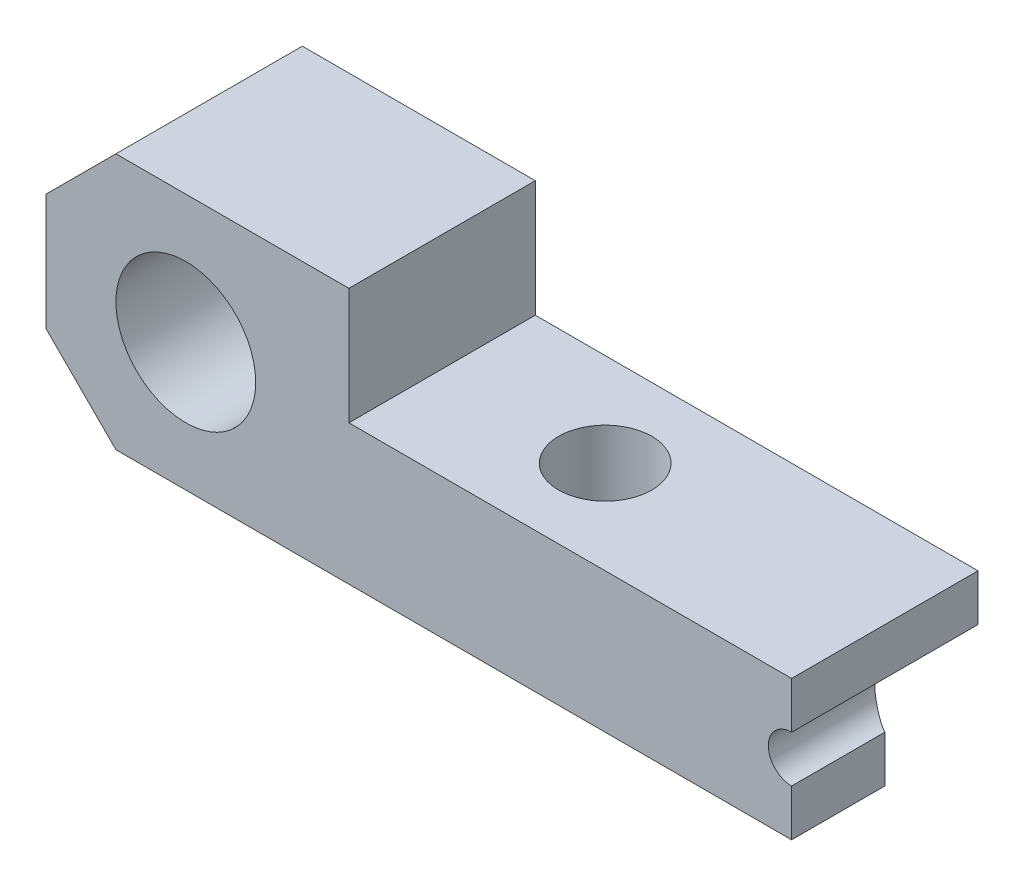
from build123d import *

# Parameters (mm, degrees)
ESQUISSE1_R             = 3
EXTRUSION1_DEPTH        = 8
ESQUISSE2_R             = 1
ENL_V_MAT_EXTRU_1_DEPTH = 9
ENL_V_MAT_EXTRU_4_DEPTH = 4
ESQUISSE4_R             = 2
ENL_V_MAT_EXTRU_5_DEPTH = 12
CHANFREIN1_SIZE         = 3


with BuildPart() as part:
    # Esquisse1 → Extrusion1 (new body)
    with BuildSketch(Plane.XY):
        Polygon((32, 6), (13, 6), (13, 11), (0, 11), (0, 0), (32, 0), align=None)
        with Locations((6, 5.5)):
            Circle(ESQUISSE1_R, mode=Mode.SUBTRACT)
    extrude(amount=EXTRUSION1_DEPTH)

    # Esquisse2 → Enlèv. mat.-Extru.1 (cut, through all)
    with BuildSketch(Plane.XY.offset(8)):
        with Locations((32, 3)):
            Circle(ESQUISSE2_R)
    extrude(amount=-ENL_V_MAT_EXTRU_1_DEPTH, mode=Mode.SUBTRACT)

    # Esquisse3 → Enlèv. mat.-Extru.4 (cut)
    with BuildSketch(Plane.XZ):
        Polygon((25, 0), (32, 4), (32, 0), align=None)
    extrude(amount=-ENL_V_MAT_EXTRU_4_DEPTH, mode=Mode.SUBTRACT)

    # Esquisse4 → Enlèv. mat.-Extru.5 (cut, through all)
    with BuildSketch(Plane.XZ):
        with Locations((20, 4)):
            Circle(ESQUISSE4_R)
    extrude(amount=-ENL_V_MAT_EXTRU_5_DEPTH, mode=Mode.SUBTRACT)

    # Chanfrein1
    chanfrein1_edges = [part.edges().sort_by_distance(p)[0] for p in [
        (0, 0, 4),
        (0, 11, 4),
    ]]
    chamfer(chanfrein1_edges, length=CHANFREIN1_SIZE)


solid = part.part
